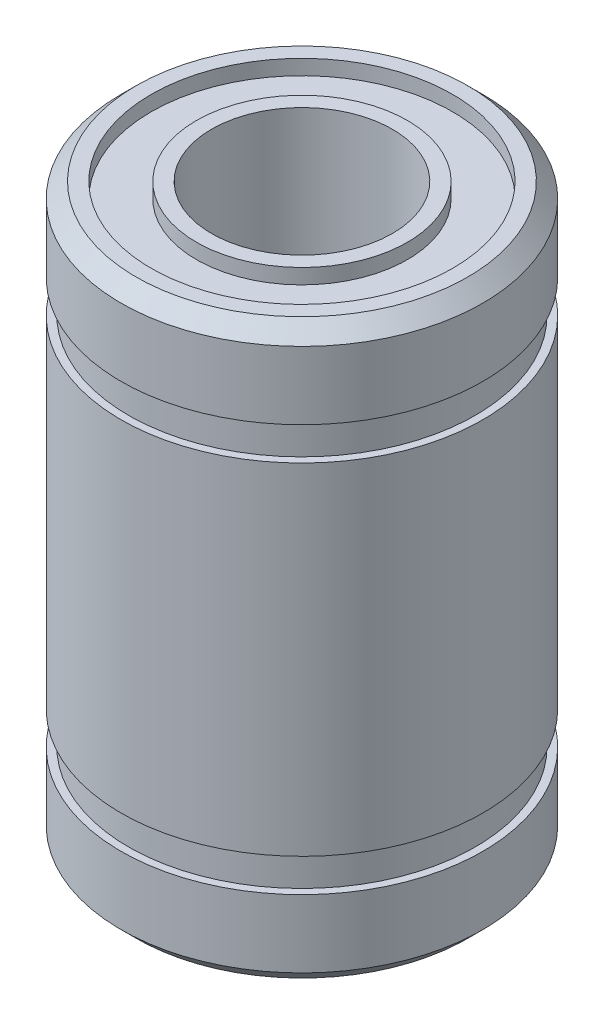
from build123d import *

# Parameters (mm, degrees)
SKETCH2_R          = 5
SKETCH2_R_2        = 3.5
CUT_EXTRUDE1_DEPTH = 0.5


with BuildPart() as part:
    # Sketch1 → Revolve1 (revolve)
    with BuildSketch(Plane.XY):
        Polygon((3, -9.5), (3, 9.5), (5.5, 9.5), (6, 9), (6, 6.75), (5.75, 6.75), (5.75, 5.65), (6, 5.65), (6, -5.65), (5.75, -5.65), (5.75, -6.75), (6, -6.75), (6, -9), (5.5, -9.5), align=None)
    revolve(axis=Axis((0, 9.5, 0), (0, -1, 0)))

    # Sketch2 → Cut-Extrude1 (cut)
    with BuildSketch(Plane(origin=(0, 9.5, 0), x_dir=(1, 0, 0), z_dir=(0, 1, 0))):
        Circle(SKETCH2_R)
        Circle(SKETCH2_R_2, mode=Mode.SUBTRACT)
    cut_extrude1 = extrude(amount=-CUT_EXTRUDE1_DEPTH, mode=Mode.SUBTRACT)

    # Mirror1: Cut-Extrude1 across plane
    add(cut_extrude1.mirror(Plane.ZX), mode=Mode.SUBTRACT)


solid = part.part
